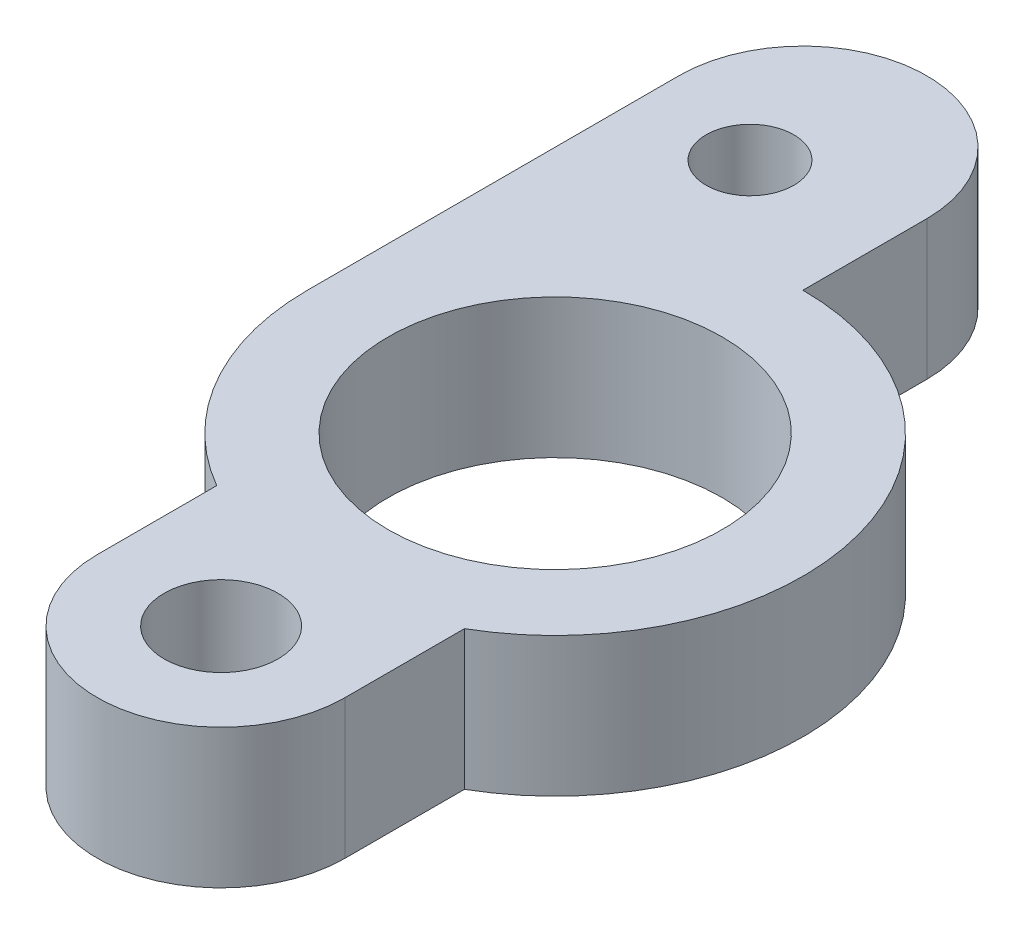
from build123d import *

# Parameters (mm, degrees)
SKETCH1_R           = 7.62
SKETCH1_R_2         = 2
SKETCH1_R_3         = 2.597919061
BOSS_EXTRUDE1_DEPTH = 6.35


with BuildPart() as part:
    # Sketch1 → Boss-Extrude1 (new body)
    with BuildSketch(Plane(origin=(0, 0, 0), x_dir=(1, 0, 0), z_dir=(0, 1, 0))):
        with BuildLine():
            Line((-11.303, 16.9545), (-11.303, 0))
            ThreePointArc((-11.303, 0), (-9.788685139, -5.6515), (-5.6515, -9.788685139))
            Line((-5.6515, -9.788685139), (-5.6515, -15.24))
            ThreePointArc((-5.6515, -15.24), (0, -20.8915), (5.6515, -15.24))
            Line((5.6515, -15.24), (5.6515, -9.788685139))
            ThreePointArc((5.6515, -9.788685139), (10.917859615, 2.925431667), (0, 11.303))
            Line((0, 11.303), (0, 16.9545))
            ThreePointArc((0, 16.9545), (-5.6515, 22.606), (-11.303, 16.9545))
        make_face()
        Circle(SKETCH1_R, mode=Mode.SUBTRACT)
        with Locations((-6.35, 15.24)):
            Circle(SKETCH1_R_2, mode=Mode.SUBTRACT)
        with Locations((0, -15.24)):
            Circle(SKETCH1_R_3, mode=Mode.SUBTRACT)
    extrude(amount=BOSS_EXTRUDE1_DEPTH)


solid = part.part
